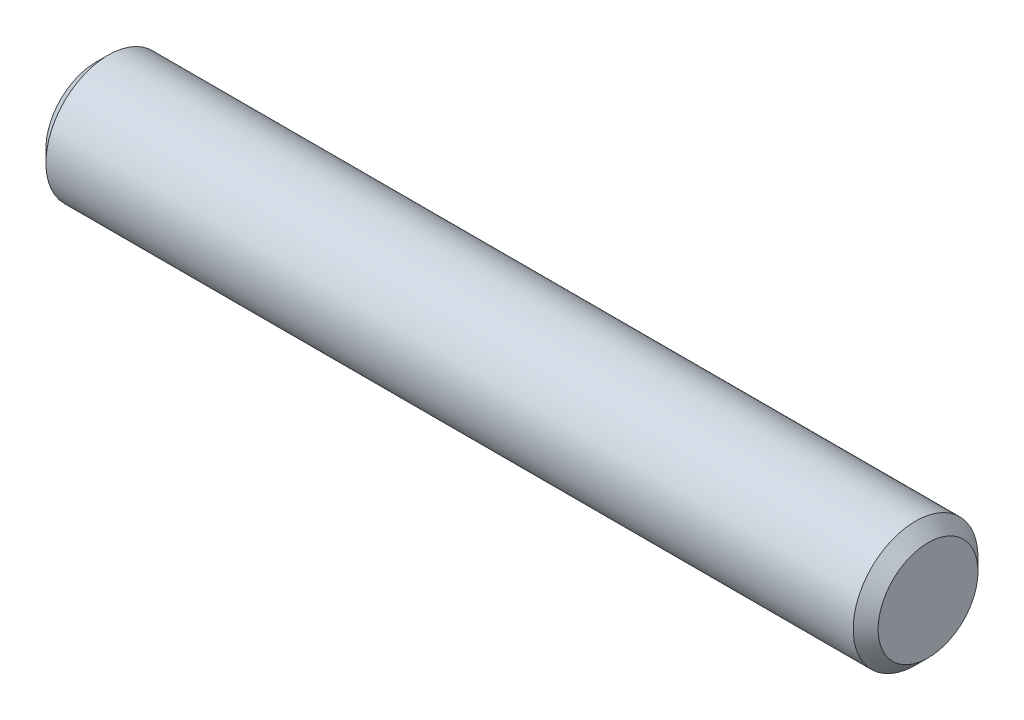
from build123d import *

# Parameters (mm, degrees)
SKETCH3_R           = 1.5
EXTRUDE1_DEPTH      = 10
EXTRUDE1_DEPTH_BACK = 10
CHAMFER1_SIZE       = 0.3


with BuildPart() as part:
    # Sketch3 → Extrude1 (new body, two sides)
    with BuildSketch(Plane(origin=(0, 0, 0), x_dir=(0, 0, -1), z_dir=(1, 0, 0))) as extrude1_sk:
        Circle(SKETCH3_R)
    extrude(amount=EXTRUDE1_DEPTH)
    extrude(extrude1_sk.sketch, amount=-EXTRUDE1_DEPTH_BACK)

    # Chamfer1
    chamfer1_edges = [part.edges().sort_by_distance(p)[0] for p in [
        (-10, 0, 1.5),
        (10, 0, 1.5),
    ]]
    chamfer(chamfer1_edges, length=CHAMFER1_SIZE)


solid = part.part
